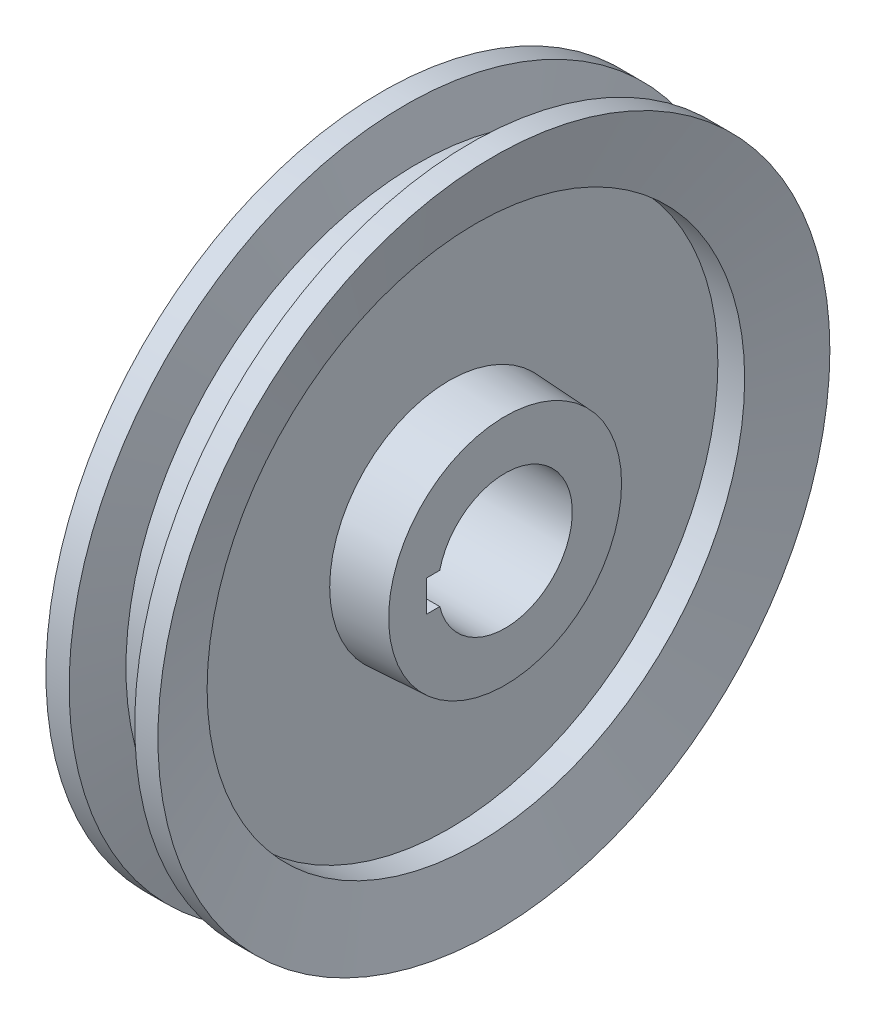
from build123d import *

# Parameters (mm, degrees)
SKETCH2_R               = 15
CUT_EXTRUDE1_DEPTH      = 16
CUT_EXTRUDE1_DEPTH_BACK = 16
SKETCH3_W               = 17.5
SKETCH3_H               = 7
CUT_EXTRUDE2_DEPTH      = 16
CUT_EXTRUDE2_DEPTH_BACK = 16


with BuildPart() as part:
    # Sketch1 → Revolve1 (revolve)
    with BuildSketch(Plane.XY):
        Polygon((12.5, 75), (8.480762114, 60), (2.5, 60), (2.5, 26.655097241), (15, 26), (15, 0), (-15, 0), (-15, 26), (-2.5, 26.655097241), (-2.5, 60), (-8.480762114, 60), (-12.5, 75), (-7.323619098, 75), (-4.644127174, 65), (4.644127174, 65), (7.323619098, 75), align=None)
    revolve(axis=Axis((15, 0, 0), (-1, 0, 0)))

    # Sketch2 → Cut-Extrude1 (cut, two sides)
    with BuildSketch(Plane(origin=(0, 0, 0), x_dir=(0, 0, -1), z_dir=(1, 0, 0))) as cut_extrude1_sk:
        Circle(SKETCH2_R)
    extrude(amount=CUT_EXTRUDE1_DEPTH, mode=Mode.SUBTRACT)
    extrude(cut_extrude1_sk.sketch, amount=-CUT_EXTRUDE1_DEPTH_BACK, mode=Mode.SUBTRACT)

    # Sketch3 → Cut-Extrude2 (cut, two sides)
    with BuildSketch(Plane(origin=(0, 0, 0), x_dir=(0, 0, -1), z_dir=(1, 0, 0))) as cut_extrude2_sk:
        with Locations((-8.75, 0)):
            Rectangle(SKETCH3_W, SKETCH3_H)
    extrude(amount=CUT_EXTRUDE2_DEPTH, mode=Mode.SUBTRACT)
    extrude(cut_extrude2_sk.sketch, amount=-CUT_EXTRUDE2_DEPTH_BACK, mode=Mode.SUBTRACT)


solid = part.part
